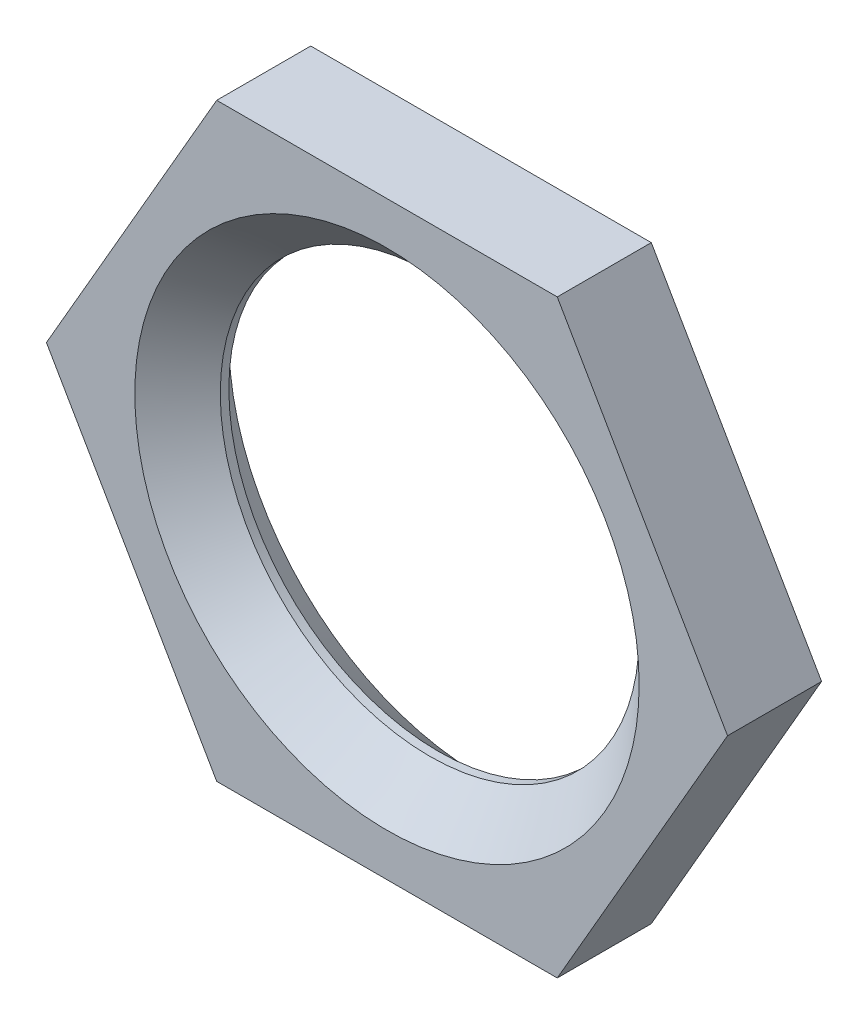
from build123d import *

# Parameters (mm, degrees)
SKETCH1_R           = 4.9
BOSS_EXTRUDE1_DEPTH = 2.2
CHAMFER1_SIZE       = 1


with BuildPart() as part:
    # Sketch1 → Boss-Extrude1 (new body)
    with BuildSketch(Plane.XY):
        Polygon((3.983716857, 6.9), (-3.983716857, 6.9), (-7.967433715, 0), (-3.983716857, -6.9), (3.983716857, -6.9), (7.967433715, 0), align=None)
        Circle(SKETCH1_R, mode=Mode.SUBTRACT)
    extrude(amount=BOSS_EXTRUDE1_DEPTH)

    # Chamfer1
    chamfer1_edges = [part.edges().sort_by_distance(p)[0] for p in [
        (-4.9, 0, 0),
        (-4.9, 0, 2.2),
    ]]
    chamfer(chamfer1_edges, length=CHAMFER1_SIZE)


solid = part.part
